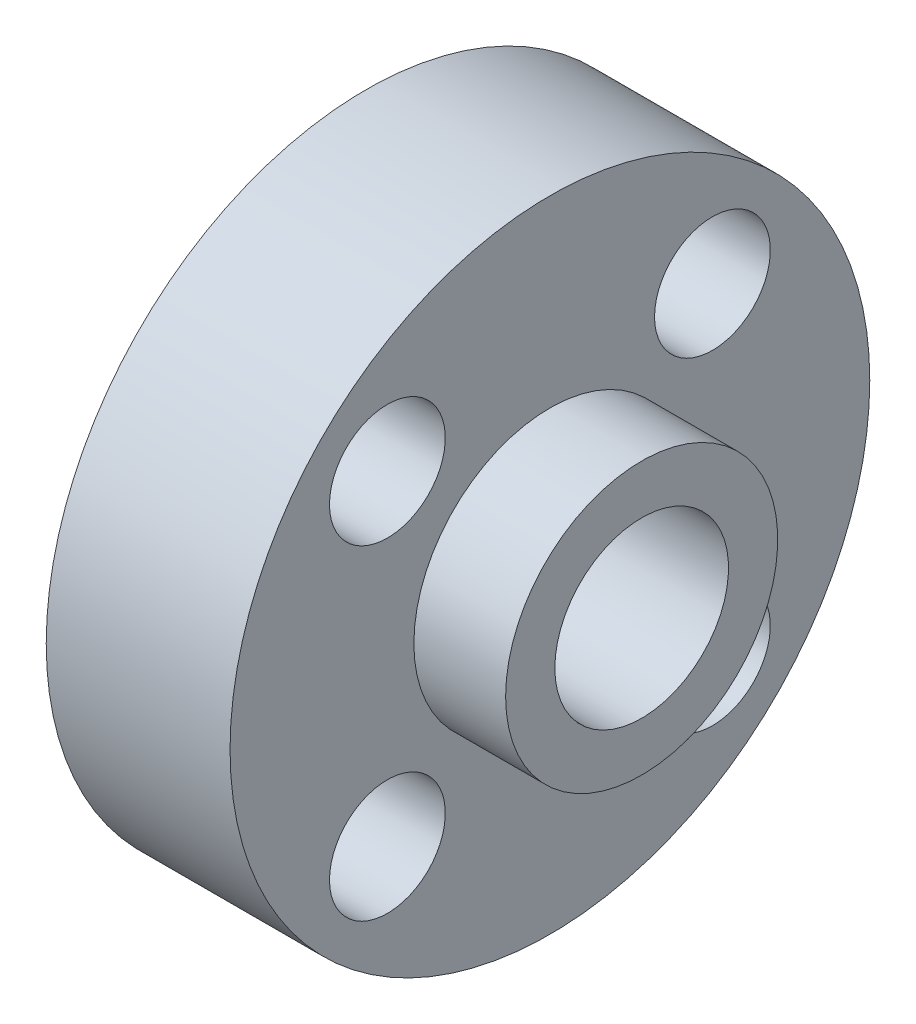
from build123d import *

# Parameters (mm, degrees)
ESQUISSE2_R                  = 3
ENL_V_MAT_EXTRU_1_DEPTH      = 13.7
ESQUISSE3_R                  = 2
ENL_V_MAT_EXTRU_2_DEPTH      = 10
R_P_TITION_CIRCULAIRE1_COUNT = 4
ESQUISSE5_R                  = 2.5
ENL_V_MAT_EXTRU_3_DEPTH      = 12.05


with BuildPart() as part:
    # Esquisse1 → Révolution1 (revolve)
    with BuildSketch(Plane(origin=(0, 0, 0), x_dir=(1, 0, 0), z_dir=(0, 1, 0))):
        Polygon((-40.200130208, 0), (-40.200130208, 4.7), (-37.020130208, 4.7), (-37.020130208, 11.05), (-30.670130208, 11.05), (-30.670130208, 4.7), (-27.500130208, 4.7), (-27.500130208, 0), align=None)
    revolve(axis=Axis((-53.297005208, 0, 0), (1, 0, 0)))

    # Esquisse2 → Enlèv. mat.-Extru.1 (cut, through all)
    with BuildSketch(Plane.ZY.offset(40.200130208)):
        Circle(ESQUISSE2_R)
    extrude(amount=-ENL_V_MAT_EXTRU_1_DEPTH, mode=Mode.SUBTRACT)

    # Esquisse3 → Enlèv. mat.-Extru.2 (cut)
    with BuildSketch(Plane.ZY.offset(37.020130208)):
        with Locations((-5.614427843, 5.614427843)):
            Circle(ESQUISSE3_R)
    enl_v_mat_extru_2 = extrude(amount=-ENL_V_MAT_EXTRU_2_DEPTH, mode=Mode.SUBTRACT)

    # Répétition circulaire1: Enlèv. mat.-Extru.2 ×4 about axis
    r_p_tition_circulaire1_axis = Axis((0, 0, 0), (1, 0, 0))
    for i in range(1, R_P_TITION_CIRCULAIRE1_COUNT):
        add(enl_v_mat_extru_2.rotate(r_p_tition_circulaire1_axis, i * 360 / R_P_TITION_CIRCULAIRE1_COUNT), mode=Mode.SUBTRACT)

    # Esquisse5 → Enlèv. mat.-Extru.3 (cut, through all)
    with BuildSketch(Plane.XY):
        with Locations((-33.845130208, 0)):
            Circle(ESQUISSE5_R)
    extrude(amount=-ENL_V_MAT_EXTRU_3_DEPTH, mode=Mode.SUBTRACT)


solid = part.part
